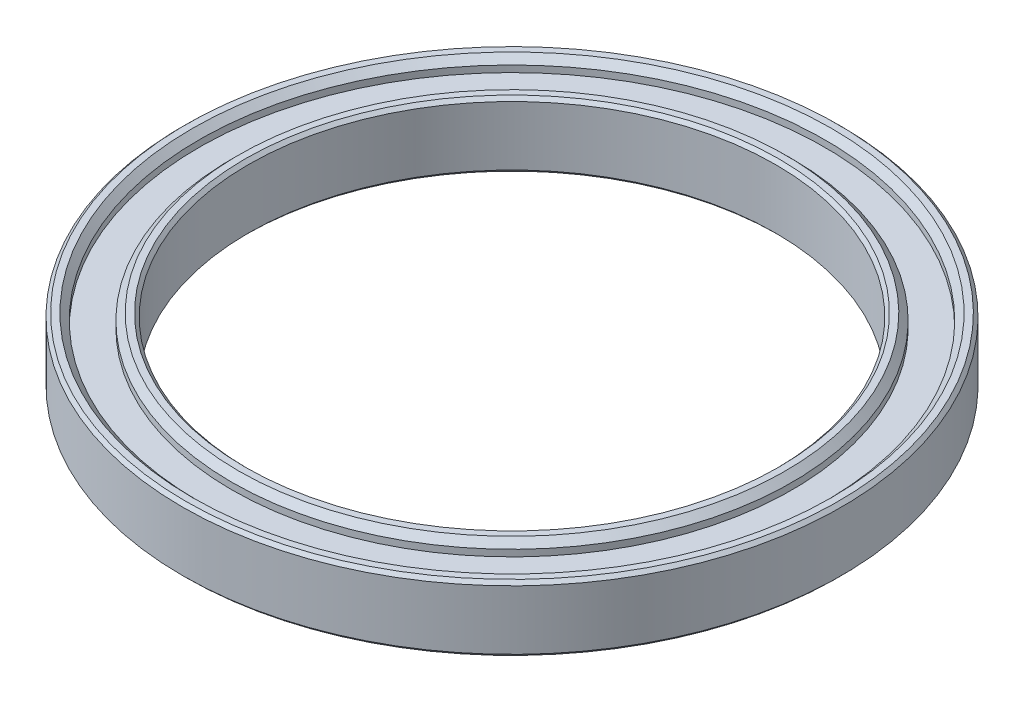
from build123d import *

# Parameters (mm, degrees)
SKETCH1_R           = 50
SKETCH1_R_2         = 40
BOSS_EXTRUDE1_DEPTH = 10
CHAMFER1_SIZE       = 0.5
SKETCH2_R           = 47.5
SKETCH2_R_2         = 42.5
CUT_EXTRUDE1_DEPTH  = 2
CHAMFER2_SIZE       = 1
SKETCH3_R           = 47.5
SKETCH3_R_2         = 42.5
CUT_EXTRUDE2_DEPTH  = 2
CHAMFER3_SIZE       = 1


with BuildPart() as part:
    # Sketch1 → Boss-Extrude1 (new body)
    with BuildSketch(Plane(origin=(0, 0, 0), x_dir=(1, 0, 0), z_dir=(0, 1, 0))):
        Circle(SKETCH1_R)
        Circle(SKETCH1_R_2, mode=Mode.SUBTRACT)
    extrude(amount=BOSS_EXTRUDE1_DEPTH)

    # Chamfer1
    chamfer1_edges = [part.edges().sort_by_distance(p)[0] for p in [
        (-50, 0, 0),
        (-50, 10, 0),
        (-40, 0, 0),
        (-40, 10, 0),
    ]]
    chamfer(chamfer1_edges, length=CHAMFER1_SIZE)

    # Sketch2 → Cut-Extrude1 (cut)
    with BuildSketch(Plane(origin=(0, 10, 0), x_dir=(1, 0, 0), z_dir=(0, 1, 0))):
        Circle(SKETCH2_R)
        Circle(SKETCH2_R_2, mode=Mode.SUBTRACT)
    extrude(amount=-CUT_EXTRUDE1_DEPTH, mode=Mode.SUBTRACT)

    # Chamfer2
    chamfer2_edges = [part.edges().sort_by_distance(p)[0] for p in [
        (-47.5, 10, 0),
        (-42.5, 10, 0),
    ]]
    chamfer(chamfer2_edges, length=CHAMFER2_SIZE)

    # Sketch3 → Cut-Extrude2 (cut)
    with BuildSketch(Plane.XZ):
        Circle(SKETCH3_R)
        Circle(SKETCH3_R_2, mode=Mode.SUBTRACT)
    extrude(amount=-CUT_EXTRUDE2_DEPTH, mode=Mode.SUBTRACT)

    # Chamfer3
    chamfer3_edges = [part.edges().sort_by_distance(p)[0] for p in [
        (-47.5, 0, 0),
        (-42.5, 0, 0),
    ]]
    chamfer(chamfer3_edges, length=CHAMFER3_SIZE)


solid = part.part
